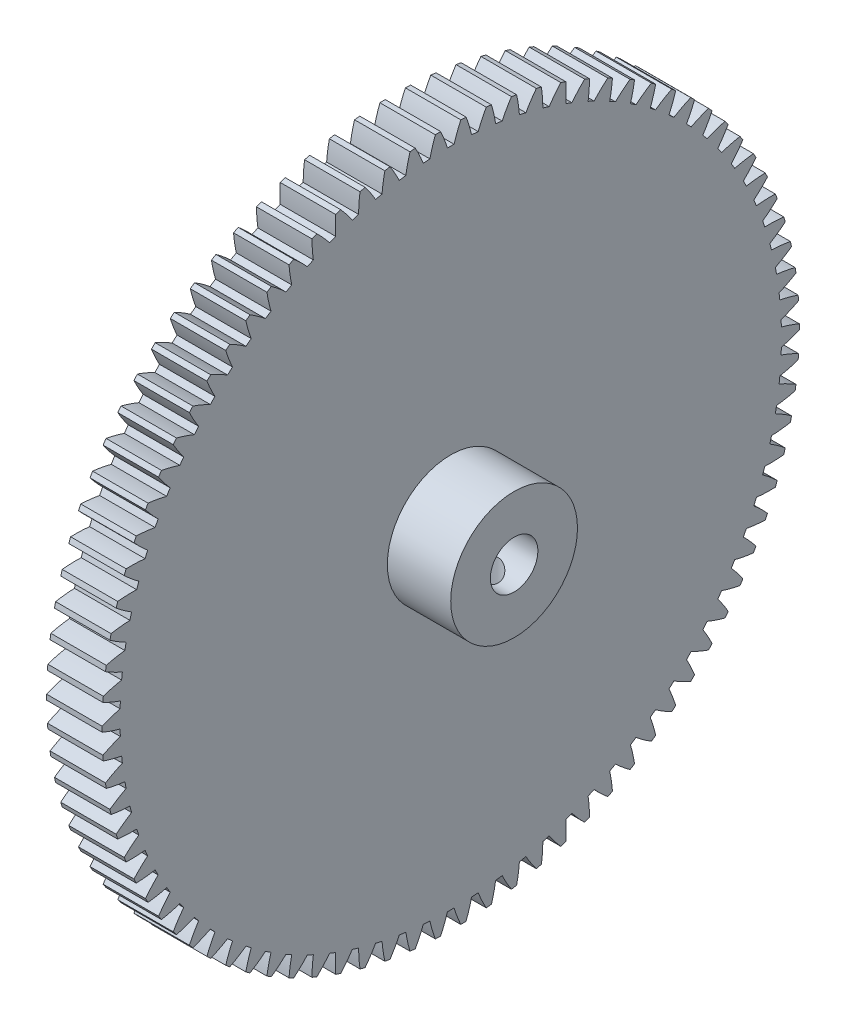
from build123d import *

# Parameters (mm, degrees)
BASPROSKE_W             = 7
BASPROSKE_H             = 44
TOOTHCUT_DEPTH          = 63.617888818
TEETHCUTS_COUNT         = 86
TEETHCUTS_ANGLE         = 355.813953488
BORSKE_R                = 3
BORE_DEPTH              = 50.0000508
SALIENTE_EXTRUIR1_START = 8
CROQUIS1_R              = 8
CROQUIS1_R_2            = 3
SALIENTE_EXTRUIR1_DEPTH = 8
CROQUIS2_R              = 2
CORTAR_EXTRUIR1_DEPTH   = 8


with BuildPart() as part:
    # BasProSke → Base-Revolve (revolve)
    with BuildSketch(Plane(origin=(0, 0, 0), x_dir=(1, 0, 0), z_dir=(0, 1, 0)), mode=Mode.PRIVATE) as base_revolve_sk:
        with Locations((3.5, 22)):
            Rectangle(BASPROSKE_W, BASPROSKE_H)
    revolve(base_revolve_sk.sketch.rotate(Axis((-10, 0, 0), (1, 0, 0)), 180), axis=Axis((-10, 0, 0), (1, 0, 0)))

    # TooCutSke → ToothCut (cut, through all)
    with BuildSketch(Plane(origin=(0, 0, 0), x_dir=(0, 0, -1), z_dir=(1, 0, 0))):
        with BuildLine():
            ThreePointArc((0.418516388, 41.746902221), (0, 41.749), (-0.418516388, 41.746902221))
            ThreePointArc((-0.418516388, 41.746902221), (-0.813225107, 42.892044552), (-1.287548276, 44.006568426))
            ThreePointArc((-1.287548276, 44.006568426), (0, 44.0254), (1.287548276, 44.006568426))
            ThreePointArc((1.287548276, 44.006568426), (0.813225107, 42.892044552), (0.418516388, 41.746902221))
        make_face()
    toothcut = extrude(amount=TOOTHCUT_DEPTH, mode=Mode.SUBTRACT)

    # TeethCuts: ToothCut ×86 about axis
    teethcuts_axis = Axis((-10, 0, 0), (1, 0, 0))
    for i in range(1, TEETHCUTS_COUNT):
        add(toothcut.rotate(teethcuts_axis, i * TEETHCUTS_ANGLE / (TEETHCUTS_COUNT - 1)), mode=Mode.SUBTRACT)

    # BorSke → Bore (cut, symmetric)
    with BuildSketch(Plane(origin=(0, 0, 0), x_dir=(0, 0, -1), z_dir=(1, 0, 0))):
        with Locations(Location((0, 0, 0), (0, 0, 180))):
            Circle(BORSKE_R)
    extrude(amount=BORE_DEPTH, both=True, mode=Mode.SUBTRACT)

    # Croquis1 → Saliente-Extruir1 (add)
    with BuildSketch(Plane(origin=(7, 0, 0), x_dir=(0, 0, -1), z_dir=(1, 0, 0)).offset(SALIENTE_EXTRUIR1_START)):
        with Locations(Location((0, 0, 0), (0, 0, 180))):
            Circle(CROQUIS1_R)
        Circle(CROQUIS1_R_2, mode=Mode.SUBTRACT)
    extrude(amount=-SALIENTE_EXTRUIR1_DEPTH)

    # Croquis2 → Cortar-Extruir1 (cut)
    with BuildSketch(Plane(origin=(0, 0, 0), x_dir=(1, 0, 0), z_dir=(0, 1, 0))):
        with Locations(Location((11, 0, 0), (0, 0, 270))):
            Circle(CROQUIS2_R)
    extrude(amount=-CORTAR_EXTRUIR1_DEPTH, mode=Mode.SUBTRACT)


solid = part.part
